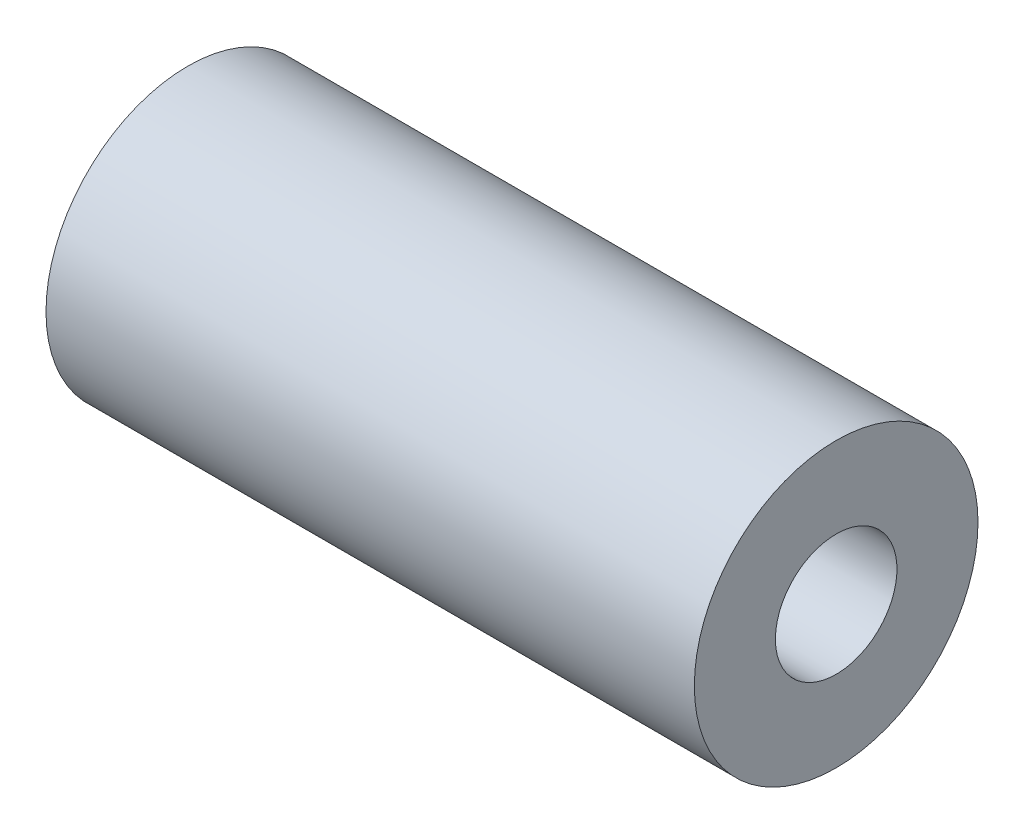
from build123d import *

# Parameters (mm, degrees)
SKETCH1_W = 32
SKETCH1_H = 4


with BuildPart() as part:
    # Sketch1 → Revolve1 (revolve)
    with BuildSketch(Plane.XY):
        with Locations((0, 5)):
            Rectangle(SKETCH1_W, SKETCH1_H)
    revolve(axis=Axis((-37.003163219, 0, 0), (1, 0, 0)))


solid = part.part
